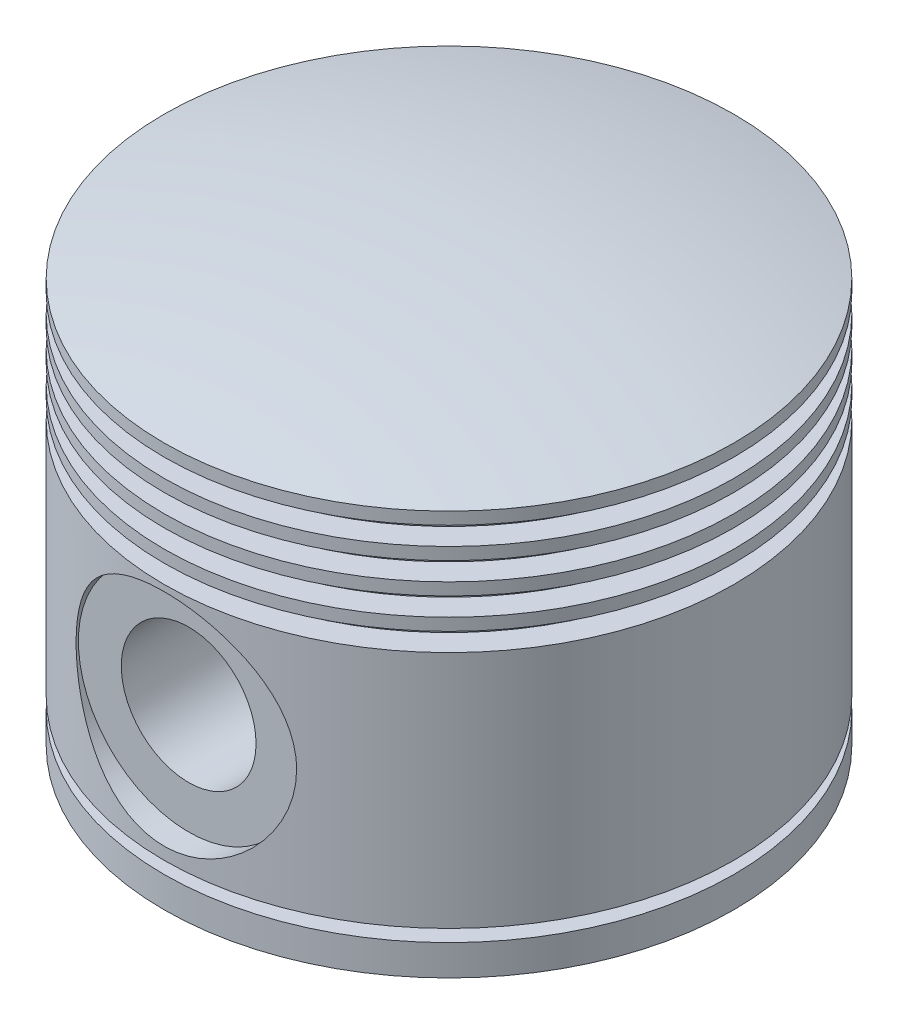
from build123d import *

# Parameters (mm, degrees)
SKETCH6_R           = 18
CUT_EXTRUDE11_DEPTH = 4
CUT_EXTRUDE12_START = -7.172957
SKETCH7_R           = 11
CUT_EXTRUDE12_DEPTH = 7.172957
SKETCH11_R          = 18
SKETCH11_R_2        = 11
BOSS_EXTRUDE1_DEPTH = 17.5


with BuildPart() as part:
    # Sketch1 → Revolve3 (revolve)
    with BuildSketch(Plane.XY):
        with BuildLine():
            ThreePointArc((-46.5, 66), (-23.430752148, 70.351520264), (0, 71.809525357))
            Line((0, 71.809525357), (0, 62))
            Line((0, 62), (-37, 62))
            Line((-37, 62), (-37, 0))
            Line((-37, 0), (-46.5, 0))
            Line((-46.5, 0), (-46.5, 5))
            Line((-46.5, 5), (-42.5, 5))
            Line((-42.5, 5), (-42.5, 7))
            Line((-42.5, 7), (-46.5, 7))
            Line((-46.5, 7), (-46.5, 46))
            Line((-46.5, 46), (-42.5, 46))
            Line((-42.5, 46), (-42.5, 49))
            Line((-42.5, 49), (-46.5, 49))
            Line((-46.5, 49), (-46.5, 51))
            Line((-46.5, 51), (-42.5, 51))
            Line((-42.5, 51), (-42.5, 54))
            Line((-42.5, 54), (-46.5, 54))
            Line((-46.5, 54), (-46.5, 56))
            Line((-46.5, 56), (-42.5, 56))
            Line((-42.5, 56), (-42.5, 59))
            Line((-42.5, 59), (-46.5, 59))
            Line((-46.5, 59), (-46.5, 61))
            Line((-46.5, 61), (-42.5, 61))
            Line((-42.5, 61), (-42.5, 64))
            Line((-42.5, 64), (-46.5, 64))
            Line((-46.5, 64), (-46.5, 66))
        make_face()
    revolve(axis=Axis((0, 71.809525357, 0), (0, -1, 0)))

    # Sketch6 → Cut-Extrude11 (cut)
    with BuildSketch(Plane.XY.offset(46.5)):
        with Locations((0, 27)):
            Circle(SKETCH6_R)
    cut_extrude11 = extrude(amount=-CUT_EXTRUDE11_DEPTH, mode=Mode.SUBTRACT)

    # Sketch7 → Cut-Extrude12 (cut)
    with BuildSketch(Plane.XY.offset(42.5).offset(CUT_EXTRUDE12_START)):
        with Locations((0, 27)):
            Circle(SKETCH7_R)
    cut_extrude12 = extrude(amount=CUT_EXTRUDE12_DEPTH, mode=Mode.SUBTRACT)

    # Sketch11 → Boss-Extrude1 (add)
    with BuildSketch(Plane.XY.offset(42.5)):
        with Locations((0, 27)):
            Circle(SKETCH11_R)
        with Locations((0, 27)):
            Circle(SKETCH11_R_2, mode=Mode.SUBTRACT)
    boss_extrude1 = extrude(amount=-BOSS_EXTRUDE1_DEPTH)

    # Mirror1: Cut-Extrude11, Cut-Extrude12, Boss-Extrude1 across plane
    add(cut_extrude11.mirror(Plane.XY), mode=Mode.SUBTRACT)
    add(cut_extrude12.mirror(Plane.XY), mode=Mode.SUBTRACT)
    add(boss_extrude1.mirror(Plane.XY))


solid = part.part
